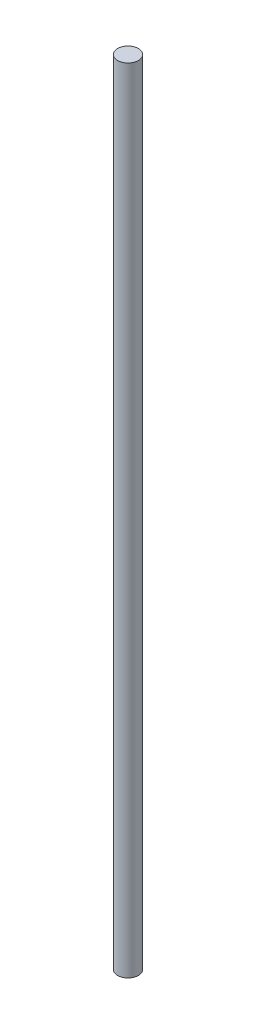
from build123d import *

# Parameters (mm, degrees)
SKETCH1_R           = 4
BOSS_EXTRUDE1_DEPTH = 304.8


with BuildPart() as part:
    # Sketch1 → Boss-Extrude1 (new body)
    with BuildSketch(Plane(origin=(0, 0, 0), x_dir=(1, 0, 0), z_dir=(0, 1, 0))):
        Circle(SKETCH1_R)
    extrude(amount=BOSS_EXTRUDE1_DEPTH)


solid = part.part
